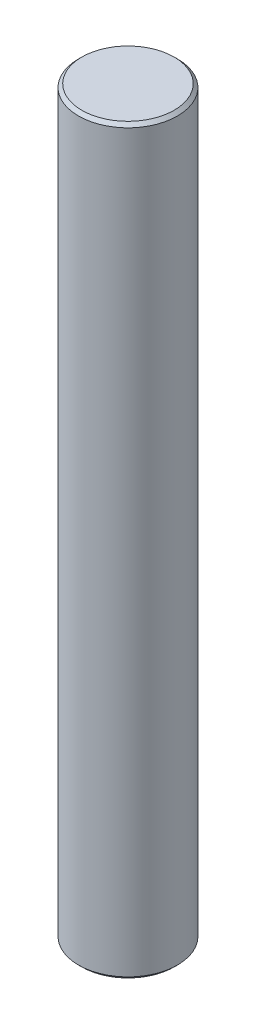
from build123d import *

# Parameters (mm, degrees)
SKETCH1_W     = 3
SKETCH1_H     = 45
CHAMFER1_SIZE = 0.2


with BuildPart() as part:
    # Sketch1 → Revolve1 (revolve)
    with BuildSketch(Plane.XY, mode=Mode.PRIVATE) as revolve1_sk:
        with Locations((1.5, 0)):
            Rectangle(SKETCH1_W, SKETCH1_H)
    revolve(revolve1_sk.sketch.rotate(Axis((0, 72.708591065, 0), (0, -1, 0)), 90), axis=Axis((0, 72.708591065, 0), (0, -1, 0)))  # turned: the seam where the file's is

    # Chamfer1
    chamfer1_edges = [part.edges().sort_by_distance(p)[0] for p in [
        (0, 22.5, -3),
        (0, -22.5, -3),
    ]]
    chamfer(chamfer1_edges, length=CHAMFER1_SIZE)


solid = part.part
